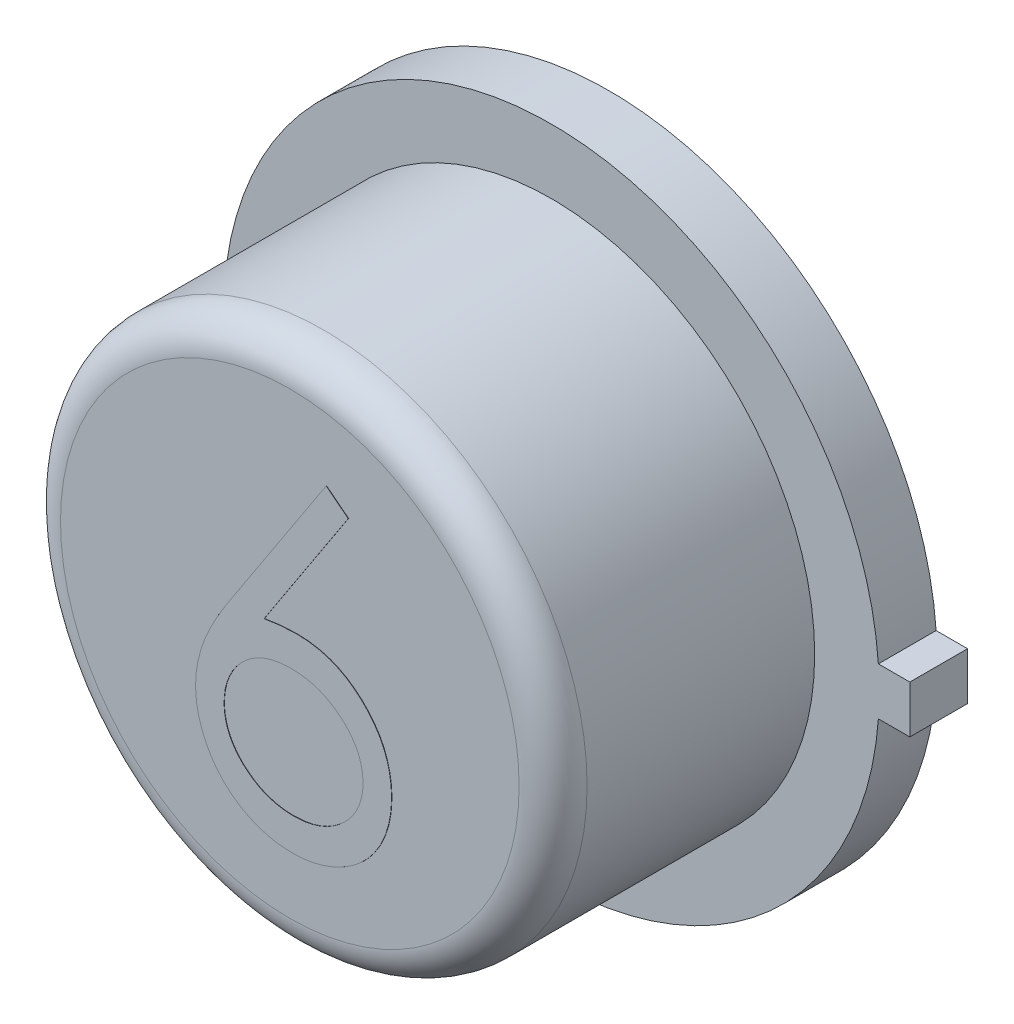
from build123d import *

# Parameters (mm, degrees)
BOSS_EXTRUDE1_DEPTH = 0.4318
SKETCH2_R           = 1.9685
BOSS_EXTRUDE2_DEPTH = 1.9558
SKETCH3_R           = 1.757566481
BOSS_EXTRUDE3_DEPTH = 0.00254
FILLET1_R           = 0.254
BOSS_EXTRUDE6_DEPTH = 0.00254


with BuildPart() as part:
    # Sketch1 → Boss-Extrude1 (new body)
    with BuildSketch(Plane.XY):
        with BuildLine():
            Line((2.6797, 0.1778), (2.4511, 0.1778))
            Line((2.4511, 0.1778), (2.44464279, 0.1778))
            ThreePointArc((2.44464279, 0.1778), (-2.4511, 0), (2.44464279, -0.1778))
            Line((2.44464279, -0.1778), (2.4511, -0.1778))
            Line((2.4511, -0.1778), (2.6797, -0.1778))
            Line((2.6797, -0.1778), (2.6797, 0.1778))
        make_face()
    extrude(amount=BOSS_EXTRUDE1_DEPTH)

    # Sketch2 → Boss-Extrude2 (add)
    with BuildSketch(Plane.XY.offset(0.4318)):
        Circle(SKETCH2_R)
    extrude(amount=BOSS_EXTRUDE2_DEPTH)

    # Sketch3 → Boss-Extrude3 (add)
    with BuildSketch(Plane(origin=(0, 0, 0), x_dir=(-1, 0, 0), z_dir=(0, 0, -1))):
        Circle(SKETCH3_R)
    extrude(amount=BOSS_EXTRUDE3_DEPTH)

    # Fillet1
    fillet1_edges = [part.edges().sort_by_distance(p)[0] for p in [
        (-1.9685, 0, 2.3876),
    ]]
    fillet(fillet1_edges, radius=FILLET1_R)

    # Sketch4 → Boss-Extrude6 (add)
    with BuildSketch(Plane.XY.offset(2.3876)):
        with BuildLine():
            Line((0.274759615, 1.224166485), (0.439329177, 1.094895902))
            Line((0.439329177, 1.094895902), (-0.189851262, 0.132760235))
            add(Edge.make_bspline(
                [(-0.189851262, 0.132760235), (-0.147961484, 0.139437166), (-0.066250736, 0.152461273), (0.016457491, 0.154609804), (0.056764573, 0.15565687)],
                knots=[0, 0, 0, 0, 0.000127097, 0.000247917, 0.000247917, 0.000247917, 0.000247917], degree=3))
            add(Edge.make_bspline(
                [(0.056764573, 0.15565687), (0.080966575, 0.155006373), (0.128607496, 0.153725888), (0.198552838, 0.143871696), (0.265764596, 0.128342469), (0.329964193, 0.105705452), (0.391382061, 0.076788671), (0.450370656, 0.042132047), (0.505821131, -5.3961e-05), (0.558447558, -0.047178868), (0.606227065, -0.099373816), (0.648528989, -0.154755797), (0.684061859, -0.213267111), (0.71289126, -0.274878122), (0.735278329, -0.339493857), (0.751598495, -0.407031645), (0.761245682, -0.477538057), (0.762555703, -0.525488387), (0.763221154, -0.549845684)],
                knots=[0, 0, 0, 0, 7.2583e-05, 0.000142877, 0.000211489, 0.000279227, 0.00034666, 0.000414888, 0.000484054, 0.000555321, 0.000626556, 0.00069601, 0.000764075, 0.000831507, 0.000899695, 0.000968882, 0.001039649, 0.001112708, 0.001112708, 0.001112708, 0.001112708], degree=3))
            add(Edge.make_bspline(
                [(0.763221154, -0.549845684), (0.762252934, -0.583169376), (0.760347707, -0.648742514), (0.74136316, -0.744248809), (0.711863116, -0.835234681), (0.669696262, -0.920247464), (0.617320748, -0.99917064), (0.553450457, -1.069101466), (0.480350513, -1.131469831), (0.397696102, -1.183623709), (0.308744192, -1.226216142), (0.21529578, -1.256808566), (0.118258382, -1.275643212), (0.052396675, -1.278004461), (0.019080529, -1.279198899)],
                knots=[0, 0, 0, 0, 9.986e-05, 0.000196501, 0.00029093, 0.000386076, 0.000480274, 0.000574162, 0.00066926, 0.000767711, 0.0008665, 0.000964399, 0.001061977, 0.001161866, 0.001161866, 0.001161866, 0.001161866], degree=3))
            add(Edge.make_bspline(
                [(0.019080529, -1.279198899), (-0.012962048, -1.278159174), (-0.076432782, -1.276099659), (-0.169800094, -1.257753191), (-0.25951404, -1.228016751), (-0.344946065, -1.187049536), (-0.424085625, -1.135303013), (-0.494887424, -1.073007962), (-0.556998435, -1.001495987), (-0.608688311, -0.920778179), (-0.649685769, -0.834039476), (-0.680431058, -0.743594732), (-0.69838993, -0.649773494), (-0.700899466, -0.586172933), (-0.702163462, -0.554138803)],
                knots=[0, 0, 0, 0, 9.605e-05, 0.000190259, 0.000284235, 0.000378964, 0.000473693, 0.000566986, 0.000660997, 0.000756925, 0.000853581, 0.000948161, 0.001042839, 0.001138919, 0.001138919, 0.001138919, 0.001138919], degree=3))
            add(Edge.make_bspline(
                [(-0.702163462, -0.554138803), (-0.701359657, -0.529615613), (-0.699718442, -0.479543946), (-0.688258921, -0.403708598), (-0.669845194, -0.32611313), (-0.649223402, -0.260285723), (-0.627434549, -0.206359581), (-0.609301303, -0.162882384), (-0.586731138, -0.118141369), (-0.562664606, -0.070602341), (-0.534935379, -0.021490466), (-0.50478491, 0.030015066), (-0.471379612, 0.08309512), (-0.447961608, 0.119116082), (-0.435990084, 0.137530368)],
                knots=[0, 0, 0, 0, 7.3559e-05, 0.000150194, 0.000229567, 0.000312689, 0.000356802, 0.000404029, 0.000453949, 0.000507071, 0.000563874, 0.000623104, 0.000686106, 0.000751998, 0.000751998, 0.000751998, 0.000751998], degree=3))
            Line((-0.435990084, 0.137530368), (0.274759615, 1.224166485))
        make_face()
        with BuildLine():
            add(Edge.make_bspline(
                [(0.011925331, -0.088573899), (-0.006214518, -0.089103247), (-0.041646912, -0.090137216), (-0.093631243, -0.09614154), (-0.14283008, -0.10744844), (-0.189895237, -0.121849105), (-0.233946799, -0.141649579), (-0.27530492, -0.165701428), (-0.314129536, -0.194018694), (-0.350013988, -0.226200207), (-0.382548438, -0.261434565), (-0.410566314, -0.299173651), (-0.434734233, -0.338507957), (-0.454384185, -0.379766135), (-0.469685468, -0.422932414), (-0.480753689, -0.467808261), (-0.486913473, -0.514694601), (-0.487938249, -0.546489393), (-0.488461538, -0.562725041)],
                knots=[0, 0, 0, 0, 5.4432e-05, 0.000106321, 0.000156664, 0.000205694, 0.00025374, 0.000301192, 0.000348994, 0.00039764, 0.000445579, 0.000492613, 0.000538426, 0.000583872, 0.000629437, 0.000675598, 0.000722282, 0.000770996, 0.000770996, 0.000770996, 0.000770996], degree=3))
            add(Edge.make_bspline(
                [(-0.488461538, -0.562725041), (-0.488035389, -0.578815474), (-0.487199773, -0.610366417), (-0.479612213, -0.656861466), (-0.468022273, -0.701605091), (-0.450781753, -0.744366625), (-0.430216674, -0.78579787), (-0.403066802, -0.824398127), (-0.372983596, -0.862511782), (-0.337024045, -0.897210997), (-0.298431899, -0.92949845), (-0.257201438, -0.957719837), (-0.214230109, -0.981863109), (-0.168937766, -1.000784588), (-0.121967008, -1.016313254), (-0.072926489, -1.027240796), (-0.021782099, -1.033418797), (0.012863005, -1.034444907), (0.030528846, -1.03496813)],
                knots=[0, 0, 0, 0, 4.8237e-05, 9.4586e-05, 0.000140984, 0.000186603, 0.000232684, 0.000279387, 0.000327886, 0.000378144, 0.000428959, 0.000478708, 0.00052782, 0.00057655, 0.000625726, 0.000676069, 0.000727011, 0.000780013, 0.000780013, 0.000780013, 0.000780013], degree=3))
            add(Edge.make_bspline(
                [(0.030528846, -1.03496813), (0.048194659, -1.034444866), (0.082839706, -1.033418676), (0.133984507, -1.027241258), (0.183023506, -1.01631156), (0.229999791, -1.000790729), (0.275271729, -0.981840327), (0.318205477, -0.957870038), (0.359046019, -0.929324894), (0.397663498, -0.897266174), (0.433473374, -0.862314287), (0.464278094, -0.824738351), (0.490596508, -0.785485897), (0.511982982, -0.744529833), (0.529033611, -0.701579235), (0.540682323, -0.656868393), (0.548254214, -0.610364604), (0.549091983, -0.578814861), (0.549519231, -0.562725041)],
                knots=[0, 0, 0, 0, 5.3002e-05, 0.000103944, 0.000154287, 0.000203463, 0.000252193, 0.000301305, 0.000350661, 0.000401476, 0.000451735, 0.000500535, 0.000546972, 0.000593272, 0.000638891, 0.000685289, 0.000731638, 0.000779875, 0.000779875, 0.000779875, 0.000779875], degree=3))
            add(Edge.make_bspline(
                [(0.549519231, -0.562725041), (0.549144835, -0.546468213), (0.548410018, -0.514561346), (0.54009881, -0.467829234), (0.528571945, -0.422704406), (0.511166347, -0.379470466), (0.488553627, -0.338298022), (0.461010451, -0.298979094), (0.429147578, -0.261212233), (0.39234193, -0.226131108), (0.352275539, -0.194054256), (0.309674578, -0.165738094), (0.26510576, -0.141840565), (0.218614275, -0.121901269), (0.16966742, -0.107512073), (0.119055422, -0.09618192), (0.066130955, -0.090152583), (0.030224013, -0.08910683), (0.011925331, -0.088573899)],
                knots=[0, 0, 0, 0, 4.8714e-05, 9.5609e-05, 0.000142007, 0.000188246, 0.000234995, 0.000282632, 0.000332044, 0.000382986, 0.000434911, 0.000485846, 0.000536213, 0.000586447, 0.0006373, 0.00068904, 0.000741877, 0.000796785, 0.000796785, 0.000796785, 0.000796785], degree=3))
        make_face(mode=Mode.SUBTRACT)
    extrude(amount=BOSS_EXTRUDE6_DEPTH)


solid = part.part
